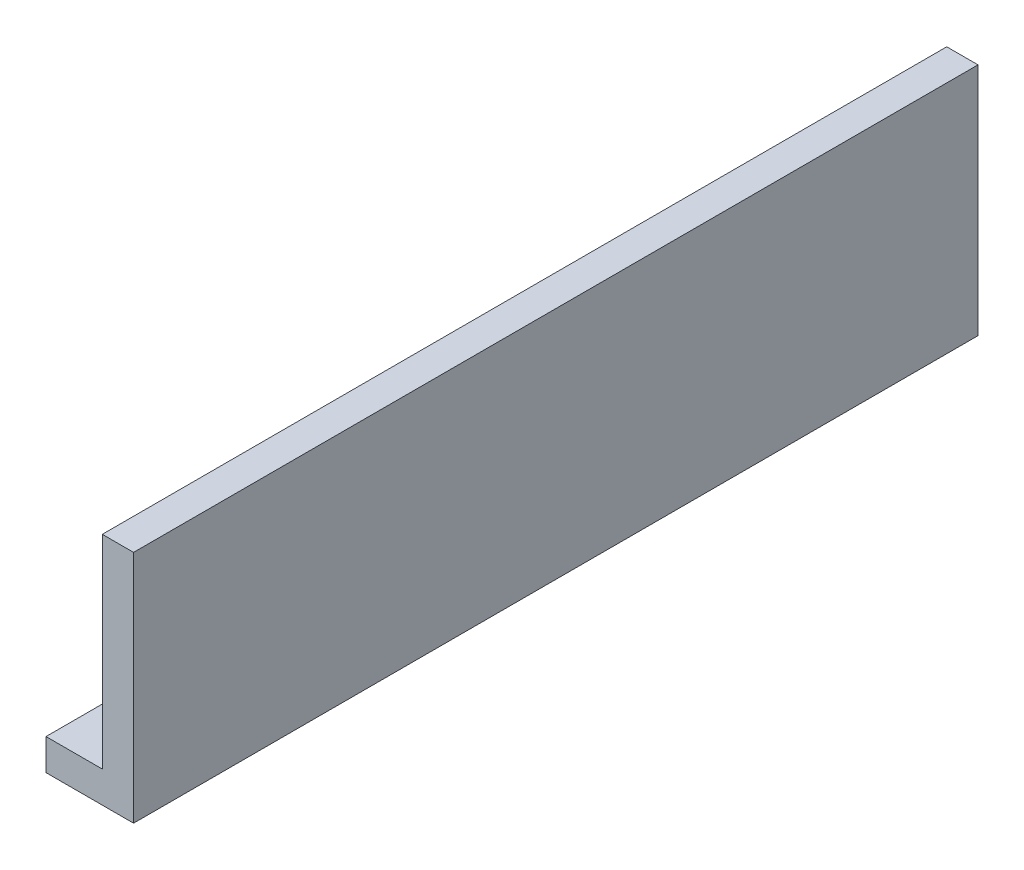
from build123d import *

# Parameters (mm, degrees)
SKETCH1_W                   = 20
SKETCH1_H                   = 540
BOSS_EXTRUDE1_DEPTH         = 150
SKETCH2_W                   = 540
SKETCH2_H                   = 20
BOSS_EXTRUDE2_DEPTH         = 36
M10_TAPPED_HOLE1_AT_2_COUNT = 2
M10_TAPPED_HOLE1_AT_2_PITCH = 80
M10_TAPPED_HOLE1_AT_3_COUNT = 2
M10_TAPPED_HOLE1_AT_3_PITCH = 160


with BuildPart() as part:
    # Sketch1 → Boss-Extrude1 (new body)
    with BuildSketch(Plane(origin=(0, 0, 0), x_dir=(1, 0, 0), z_dir=(0, 1, 0))):
        with Locations((10, 0)):
            Rectangle(SKETCH1_W, SKETCH1_H)
    extrude(amount=BOSS_EXTRUDE1_DEPTH)

    # Sketch2 → Boss-Extrude2 (add)
    with BuildSketch(Plane(origin=(0, 0, 0), x_dir=(0, 0, -1), z_dir=(1, 0, 0))):
        with Locations((0, 10)):
            Rectangle(SKETCH2_W, SKETCH2_H)
    extrude(amount=-BOSS_EXTRUDE2_DEPTH)

    # Sketch6 → M10 Tapped Hole1 (revolve, cut)
    with BuildSketch(Plane(origin=(-16, 20, -80), x_dir=(0, 0, 1), z_dir=(1, 0, 0))):
        Polygon((0, 0), (0, 27.5), (4.25, 24.946342369), (4.25, 0.775), (5.025, 0), align=None)
    m10_tapped_hole1 = revolve(axis=Axis((-16, 26.35, -80), (0, -1, 0)), mode=Mode.SUBTRACT)

    # M10 Tapped Hole1 at 2: M10 Tapped Hole1 ×2
    with Locations(*[(0, 0, -i * M10_TAPPED_HOLE1_AT_2_PITCH) for i in range(1, M10_TAPPED_HOLE1_AT_2_COUNT)]):
        add(m10_tapped_hole1, mode=Mode.SUBTRACT)

    # M10 Tapped Hole1 at 3: M10 Tapped Hole1 ×2
    with Locations(*[(0, 0, -i * M10_TAPPED_HOLE1_AT_3_PITCH) for i in range(1, M10_TAPPED_HOLE1_AT_3_COUNT)]):
        add(m10_tapped_hole1, mode=Mode.SUBTRACT)

    # Mirror1: M10 Tapped Hole1 across plane
    add(m10_tapped_hole1.mirror(Plane.XY), mode=Mode.SUBTRACT)

    # Mirror1 copy 1 sketch → Mirror1 copy 1 (revolve, cut)
    with BuildSketch(Plane(origin=(-16, 20, 160), x_dir=(0, 0, -1), z_dir=(1, 0, 0))):
        Polygon((0, 0), (0, -27.5), (4.25, -24.946342369), (4.25, -0.775), (5.025, 0), align=None)
    revolve(axis=Axis((-16, 26.35, 160), (0, 1, 0)), mode=Mode.SUBTRACT)

    # Mirror1 copy 2 sketch → Mirror1 copy 2 (revolve, cut)
    with BuildSketch(Plane(origin=(-16, 20, 240), x_dir=(0, 0, -1), z_dir=(1, 0, 0))):
        Polygon((0, 0), (0, -27.5), (4.25, -24.946342369), (4.25, -0.775), (5.025, 0), align=None)
    revolve(axis=Axis((-16, 26.35, 240), (0, 1, 0)), mode=Mode.SUBTRACT)


solid = part.part
